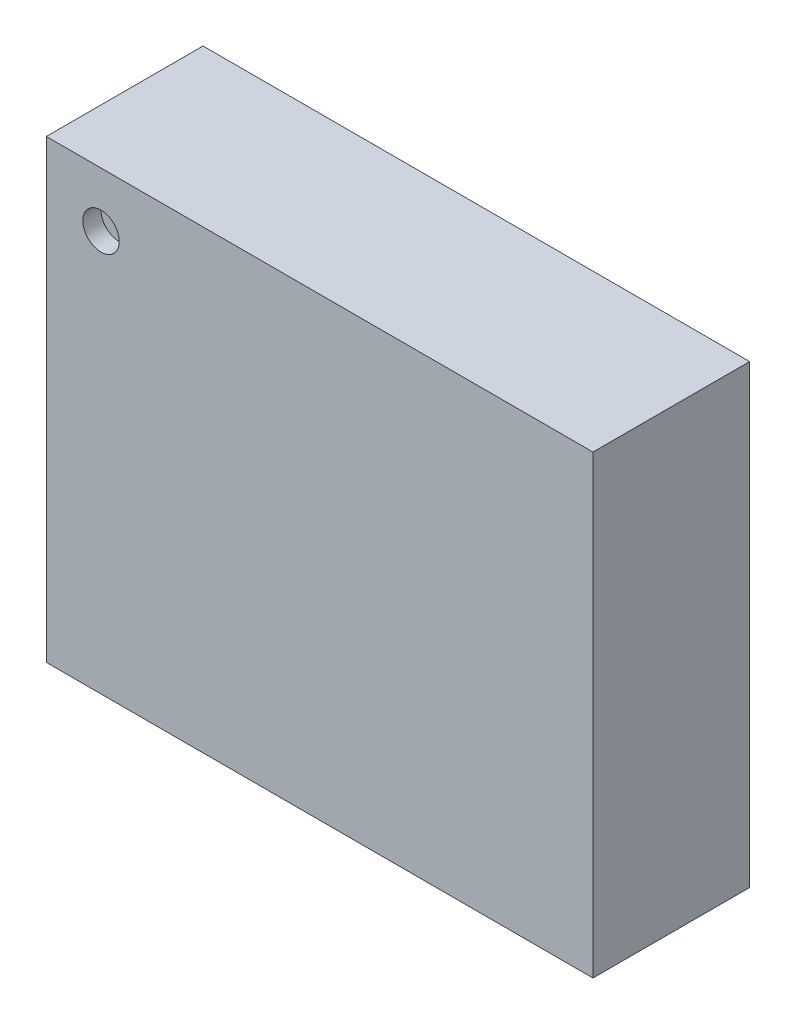
from build123d import *

# Parameters (mm, degrees)
SKETCH1_W           = 3
SKETCH1_H           = 2.5
BOSS_EXTRUDE1_DEPTH = 0.86
SKETCH2_R           = 0.1
CUT_EXTRUDE1_DEPTH  = 0.1
SKETCH3_W           = 0.25
SKETCH3_H           = 0.45
SKETCH3_W_2         = 0.45
SKETCH3_H_2         = 0.25
BOSS_EXTRUDE2_DEPTH = 0.05


with BuildPart() as part:
    # Sketch1 → Boss-Extrude1 (new body)
    with BuildSketch(Plane.XY):
        with Locations((1.5, 1.25)):
            Rectangle(SKETCH1_W, SKETCH1_H)
    extrude(amount=BOSS_EXTRUDE1_DEPTH)

    # Sketch2 → Cut-Extrude1 (cut)
    with BuildSketch(Plane.XY.offset(0.86)):
        with Locations((0.3, 2.2)):
            Circle(SKETCH2_R)
    extrude(amount=-CUT_EXTRUDE1_DEPTH, mode=Mode.SUBTRACT)

    # Sketch3 → Boss-Extrude2 (add)
    with BuildSketch(Plane(origin=(0, 0, 0), x_dir=(-1, 0, 0), z_dir=(0, 0, -1))):
        with Locations((-1, 2.175)):
            Rectangle(SKETCH3_W, SKETCH3_H)
        with Locations((-1.5, 2.175)):
            Rectangle(SKETCH3_W, SKETCH3_H)
        with Locations((-2, 2.175)):
            Rectangle(SKETCH3_W, SKETCH3_H)
        with Locations((-2, 0.325)):
            Rectangle(SKETCH3_W, SKETCH3_H)
        with Locations((-1.5, 0.325)):
            Rectangle(SKETCH3_W, SKETCH3_H)
        with Locations((-1, 0.325)):
            Rectangle(SKETCH3_W, SKETCH3_H)
        with Locations((-2.675, 2)):
            Rectangle(SKETCH3_W_2, SKETCH3_H_2)
        with Locations((-2.675, 1.5)):
            Rectangle(SKETCH3_W_2, SKETCH3_H_2)
        with Locations((-2.675, 1)):
            Rectangle(SKETCH3_W_2, SKETCH3_H_2)
        with Locations((-2.675, 0.5)):
            Rectangle(SKETCH3_W_2, SKETCH3_H_2)
        with Locations((-0.325, 0.5)):
            Rectangle(SKETCH3_W_2, SKETCH3_H_2)
        with Locations((-0.325, 1)):
            Rectangle(SKETCH3_W_2, SKETCH3_H_2)
        with Locations((-0.325, 1.5)):
            Rectangle(SKETCH3_W_2, SKETCH3_H_2)
        Polygon((-0.55, 2.125), (-0.55, 2), (-0.427001114, 1.875), (-0.1, 1.875), (-0.1, 2.125), align=None)
    extrude(amount=BOSS_EXTRUDE2_DEPTH)


solid = part.part
